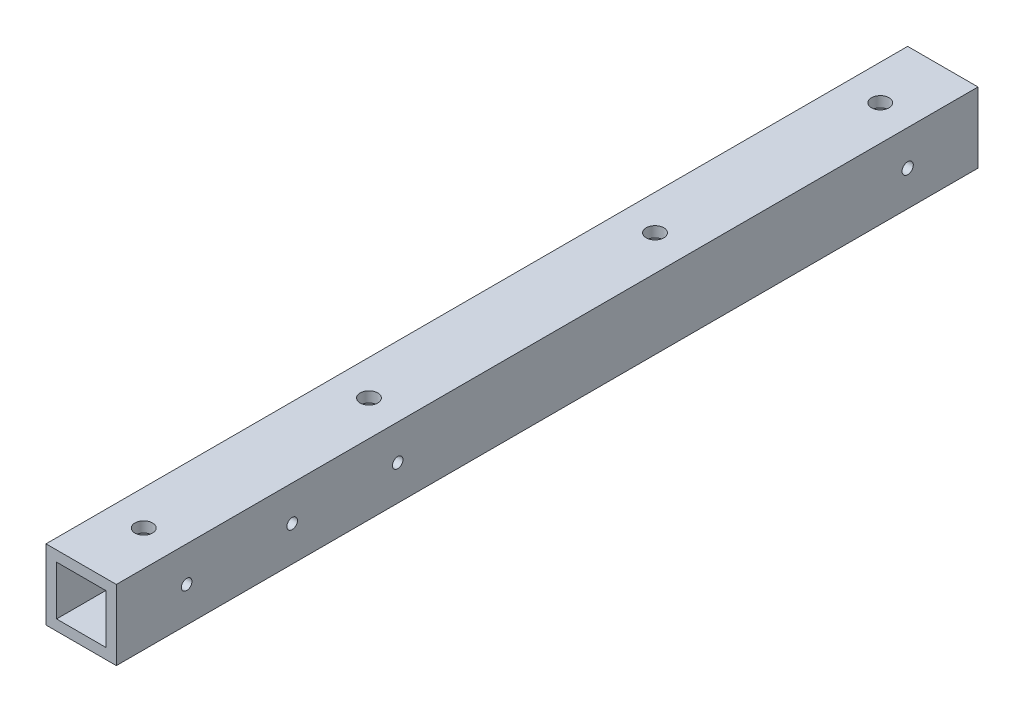
from build123d import *

# Parameters (mm, degrees)
SKETCH_1_W          = 20
SKETCH_1_H          = 20
EXTRUDE_1_DEPTH     = 245
SKETCH_2_W          = 14
SKETCH_2_H          = 14
CUT_EXTRUDE_1_DEPTH = 246
SKETCH_3_R          = 1.5
SKETCH_3_R_2        = 1.6
CUT_EXTRUDE_2_DEPTH = 80
SKETCH_4_R          = 2.5
CUT_EXTRUDE_3_DEPTH = 93


with BuildPart() as part:
    # 草图1 → 凸台-拉伸1 (new body)
    with BuildSketch(Plane.XY):
        with Locations((0.666666667, 1.006147649)):
            Rectangle(SKETCH_1_W, SKETCH_1_H)
    extrude(amount=EXTRUDE_1_DEPTH)

    # 草图2 → 切除-拉伸1 (cut, through all)
    with BuildSketch(Plane(origin=(0, 0, 0), x_dir=(-1, 0, 0), z_dir=(0, 0, -1))):
        with Locations((-0.666666667, 1.006147649)):
            Rectangle(SKETCH_2_W, SKETCH_2_H)
    extrude(amount=-CUT_EXTRUDE_1_DEPTH, mode=Mode.SUBTRACT)

    # 草图3 → 切除-拉伸2 (cut)
    with BuildSketch(Plane.ZY.offset(9.333333333)):
        with Locations((225, 1.006147649)):
            Circle(SKETCH_3_R)
        with Locations((195, 1.006147649)):
            Circle(SKETCH_3_R)
        with Locations((165, 1.006147649)):
            Circle(SKETCH_3_R)
        with Locations((20, 1.006147649)):
            Circle(SKETCH_3_R_2)
    extrude(amount=-CUT_EXTRUDE_2_DEPTH, mode=Mode.SUBTRACT)

    # 草图4 → 切除-拉伸3 (cut)
    with BuildSketch(Plane(origin=(0, 11.006147649, 0), x_dir=(1, 0, 0), z_dir=(0, 1, 0))):
        with Locations((0.666666667, -17.788232679)):
            Circle(SKETCH_4_R)
        with Locations((0.666666667, -81.833059371)):
            Circle(SKETCH_4_R)
        with Locations((0.666666667, -163.166940629)):
            Circle(SKETCH_4_R)
        with Locations((0.666666667, -227.211767321)):
            Circle(SKETCH_4_R)
    extrude(amount=-CUT_EXTRUDE_3_DEPTH, mode=Mode.SUBTRACT)


solid = part.part
